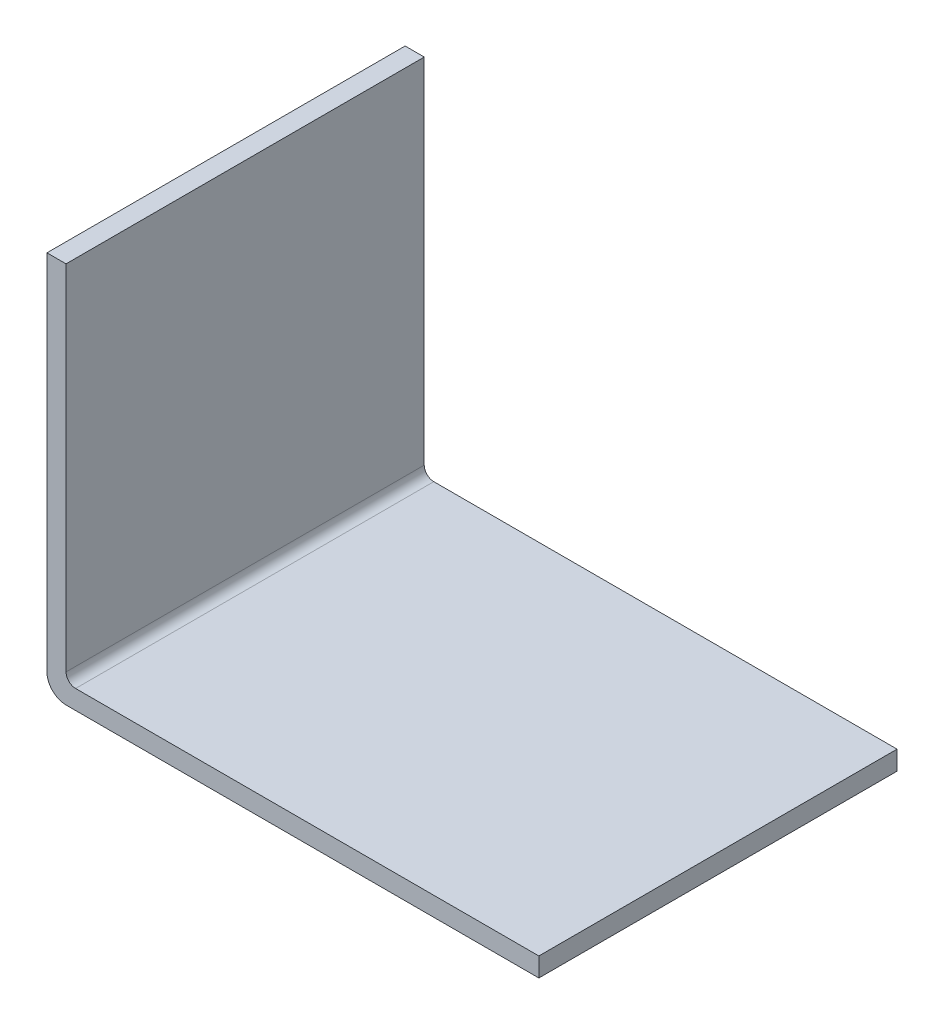
from build123d import *

# Parameters (mm, degrees)
SKETCH1_W           = 51.5
SKETCH1_H           = 37.5
BOSS_EXTRUDE1_DEPTH = 40
SKETCH2_W           = 49.5
SKETCH2_H           = 38
CUT_EXTRUDE1_DEPTH  = 38.5
FILLET1_R           = 1
FILLET2_R           = 2


with BuildPart() as part:
    # Sketch1 → Boss-Extrude1 (new body)
    with BuildSketch(Plane(origin=(0, 0, 0), x_dir=(1, 0, 0), z_dir=(0, 1, 0))):
        Rectangle(SKETCH1_W, SKETCH1_H)
    extrude(amount=BOSS_EXTRUDE1_DEPTH)

    # Sketch2 → Cut-Extrude1 (cut, through all)
    with BuildSketch(Plane.XY.offset(18.75)):
        with Locations((1, 21)):
            Rectangle(SKETCH2_W, SKETCH2_H)
    extrude(amount=-CUT_EXTRUDE1_DEPTH, mode=Mode.SUBTRACT)

    # Fillet1
    fillet1_edges = [part.edges().sort_by_distance(p)[0] for p in [
        (-23.75, 2, 0),
    ]]
    fillet(fillet1_edges, radius=FILLET1_R)

    # Fillet2
    fillet2_edges = [part.edges().sort_by_distance(p)[0] for p in [
        (-25.75, 0, 0),
    ]]
    fillet(fillet2_edges, radius=FILLET2_R)


solid = part.part
